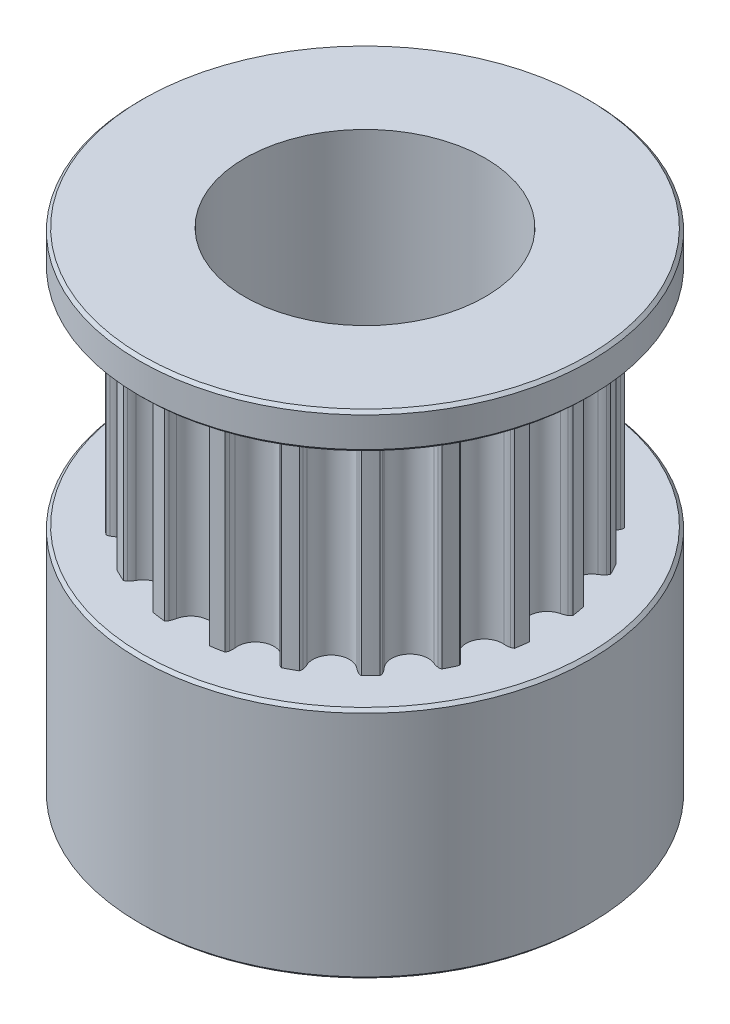
from build123d import *

# Parameters (mm, degrees)
P_IDAT_START            = 7.8
SKICA1_R                = 4
P_IDAT_VYSUNUT_M1_DEPTH = 7.4
SKICA2_R                = 4.5
SKICA2_R_2              = 4
P_IDAT_VYSUNUT_M2_DEPTH = 7.8
SKICA3_R                = 4
SKICA3_R_2              = 3.5
P_IDAT_VYSUNUT_M3_DEPTH = 1.2
SKICA5_R                = 7.5
SKICA5_R_2              = 3.5
P_IDAT_VYSUNUT_M4_DEPTH = 1.2
SKICA6_R                = 7.5
SKICA6_R_2              = 4
P_IDAT_VYSUNUT_M5_DEPTH = 7.8
ZKOSEN_1_SIZE           = 0.1
ZKOSEN_3_SIZE           = 0.1
SKETCH1_R               = 4
CUT_EXTRUDE1_DEPTH      = 2.2


with BuildPart() as part:
    # Skica1 → Přidat vysunutím1 (new body)
    with BuildSketch(Plane(origin=(0, 0, 0), x_dir=(1, 0, 0), z_dir=(0, 1, 0)).offset(P_IDAT_START)):
        with BuildLine():
            ThreePointArc((-5.730143195, 1.098270155), (-5.09645097, 1.530497044), (-5.387174672, 2.240331989))
            ThreePointArc((-5.387174672, 2.240331989), (-5.468060657, 2.292707421), (-5.540463547, 2.356296335))
            ThreePointArc((-5.540463547, 2.356296335), (-5.573874331, 2.399596558), (-5.596043873, 2.44959357))
            ThreePointArc((-5.596043873, 2.44959357), (-5.50369925, 2.650567912), (-5.404139771, 2.848067596))
            ThreePointArc((-5.404139771, 2.848067596), (-5.351227535, 2.86190541), (-5.296542742, 2.862779021))
            ThreePointArc((-5.296542742, 2.862779021), (-5.201685094, 2.845815675), (-5.110305882, 2.815228615))
            ThreePointArc((-5.110305882, 2.815228615), (-4.374063308, 3.030479148), (-4.431206919, 3.795410862))
            ThreePointArc((-4.431206919, 3.795410862), (-4.491949163, 3.870218002), (-4.541158349, 3.953068377))
            ThreePointArc((-4.541158349, 3.953068377), (-4.559553388, 4.004573836), (-4.565187949, 4.058974585))
            ThreePointArc((-4.565187949, 4.058974585), (-4.415258506, 4.221576484), (-4.259541056, 4.378644275))
            ThreePointArc((-4.259541056, 4.378644275), (-4.204942409, 4.375454038), (-4.15266412, 4.359386362))
            ThreePointArc((-4.15266412, 4.359386362), (-4.067691098, 4.313940635), (-3.990236225, 4.256612884))
            ThreePointArc((-3.990236225, 4.256612884), (-3.223511854, 4.233816838), (-3.041481758, 4.978968476))
            ThreePointArc((-3.041481758, 4.978968476), (-3.076134388, 5.06888468), (-3.097332931, 5.162886543))
            ThreePointArc((-3.097332931, 5.162886543), (-3.09891159, 5.217555525), (-3.08745962, 5.271034888))
            ThreePointArc((-3.08745962, 5.271034888), (-2.894621497, 5.379347737), (-2.697988784, 5.480608745))
            ThreePointArc((-2.697988784, 5.480608745), (-2.647048223, 5.460702739), (-2.6022938, 5.429266591))
            ThreePointArc((-2.6022938, 5.429266591), (-2.535523156, 5.359787029), (-2.479574443, 5.281330225))
            ThreePointArc((-2.479574443, 5.281330225), (-1.7574206, 5.022719037), (-1.354035171, 5.675149965))
            ThreePointArc((-1.354035171, 5.675149965), (-1.359206146, 5.771373608), (-1.350318985, 5.867325402))
            ThreePointArc((-1.350318985, 5.867325402), (-1.334926735, 5.919806527), (-1.307509232, 5.967129569))
            ThreePointArc((-1.307509232, 5.967129569), (-1.090638767, 6.010550954), (-0.872338572, 6.046093045))
            ThreePointArc((-0.872338572, 6.046093045), (-0.830042514, 6.01141981), (-0.797192832, 5.967692379))
            ThreePointArc((-0.797192832, 5.967692379), (-0.755160541, 5.880980125), (-0.726194639, 5.789074167))
            ThreePointArc((-0.726194639, 5.789074167), (-0.119300773, 5.319962501), (0.465953812, 5.815808234))
            ThreePointArc((0.465953812, 5.815808234), (0.490770664, 5.908920276), (0.528873591, 5.997429571))
            ThreePointArc((0.528873591, 5.997429571), (0.55973005, 6.04258562), (0.600429269, 6.079120034))
            ThreePointArc((0.600429269, 6.079120034), (0.820103284, 6.053399565), (1.038702217, 6.019743632))
            ThreePointArc((1.038702217, 6.019743632), (1.06821354, 5.973697225), (1.085942924, 5.921958857))
            ThreePointArc((1.085942924, 5.921958857), (1.099122448, 5.826501911), (1.098270155, 5.730143195))
            ThreePointArc((1.098270155, 5.730143195), (1.530497044, 5.09645097), (2.240331989, 5.387174672))
            ThreePointArc((2.240331989, 5.387174672), (2.292707421, 5.468060657), (2.356296335, 5.540463547))
            ThreePointArc((2.356296335, 5.540463547), (2.399596558, 5.573874331), (2.44959357, 5.596043873))
            ThreePointArc((2.44959357, 5.596043873), (2.650567912, 5.50369925), (2.848067596, 5.404139771))
            ThreePointArc((2.848067596, 5.404139771), (2.86190541, 5.351227535), (2.862779021, 5.296542742))
            ThreePointArc((2.862779021, 5.296542742), (2.845815675, 5.201685094), (2.815228615, 5.110305882))
            ThreePointArc((2.815228615, 5.110305882), (3.030479148, 4.374063308), (3.795410862, 4.431206919))
            ThreePointArc((3.795410862, 4.431206919), (3.870218002, 4.491949163), (3.953068377, 4.541158349))
            ThreePointArc((3.953068377, 4.541158349), (4.004573836, 4.559553388), (4.058974585, 4.565187949))
            ThreePointArc((4.058974585, 4.565187949), (4.221576484, 4.415258506), (4.378644275, 4.259541056))
            ThreePointArc((4.378644275, 4.259541056), (4.375454038, 4.204942409), (4.359386362, 4.15266412))
            ThreePointArc((4.359386362, 4.15266412), (4.313940635, 4.067691098), (4.256612884, 3.990236225))
            ThreePointArc((4.256612884, 3.990236225), (4.233816838, 3.223511854), (4.978968476, 3.041481758))
            ThreePointArc((4.978968476, 3.041481758), (5.06888468, 3.076134388), (5.162886543, 3.097332931))
            ThreePointArc((5.162886543, 3.097332931), (5.217555525, 3.09891159), (5.271034888, 3.08745962))
            ThreePointArc((5.271034888, 3.08745962), (5.379347737, 2.894621497), (5.480608745, 2.697988784))
            ThreePointArc((5.480608745, 2.697988784), (5.460702739, 2.647048223), (5.429266591, 2.6022938))
            ThreePointArc((5.429266591, 2.6022938), (5.359787029, 2.535523156), (5.281330225, 2.479574443))
            ThreePointArc((5.281330225, 2.479574443), (5.022719037, 1.7574206), (5.675149965, 1.354035171))
            ThreePointArc((5.675149965, 1.354035171), (5.771373608, 1.359206146), (5.867325402, 1.350318985))
            ThreePointArc((5.867325402, 1.350318985), (5.919806527, 1.334926735), (5.967129569, 1.307509232))
            ThreePointArc((5.967129569, 1.307509232), (6.010550954, 1.090638767), (6.046093045, 0.872338572))
            ThreePointArc((6.046093045, 0.872338572), (6.01141981, 0.830042514), (5.967692379, 0.797192832))
            ThreePointArc((5.967692379, 0.797192832), (5.880980125, 0.755160541), (5.789074167, 0.726194639))
            ThreePointArc((5.789074167, 0.726194639), (5.319962501, 0.119300773), (5.815808234, -0.465953812))
            ThreePointArc((5.815808234, -0.465953812), (5.908920276, -0.490770664), (5.997429571, -0.528873591))
            ThreePointArc((5.997429571, -0.528873591), (6.04258562, -0.55973005), (6.079120034, -0.600429269))
            ThreePointArc((6.079120034, -0.600429269), (6.053399565, -0.820103284), (6.019743632, -1.038702217))
            ThreePointArc((6.019743632, -1.038702217), (5.973697225, -1.06821354), (5.921958857, -1.085942924))
            ThreePointArc((5.921958857, -1.085942924), (5.826501911, -1.099122448), (5.730143195, -1.098270155))
            ThreePointArc((5.730143195, -1.098270155), (5.09645097, -1.530497044), (5.387174672, -2.240331989))
            ThreePointArc((5.387174672, -2.240331989), (5.468060657, -2.292707421), (5.540463547, -2.356296335))
            ThreePointArc((5.540463547, -2.356296335), (5.573874331, -2.399596558), (5.596043873, -2.44959357))
            ThreePointArc((5.596043873, -2.44959357), (5.50369925, -2.650567911), (5.404139771, -2.848067596))
            ThreePointArc((5.404139771, -2.848067596), (5.351227535, -2.86190541), (5.296542742, -2.862779021))
            ThreePointArc((5.296542742, -2.862779021), (5.201685094, -2.845815675), (5.110305882, -2.815228615))
            ThreePointArc((5.110305882, -2.815228615), (4.374063308, -3.030479148), (4.431206919, -3.795410862))
            ThreePointArc((4.431206919, -3.795410862), (4.491949163, -3.870218002), (4.541158349, -3.953068377))
            ThreePointArc((4.541158349, -3.953068377), (4.559553388, -4.004573836), (4.565187949, -4.058974585))
            ThreePointArc((4.565187949, -4.058974585), (4.415258506, -4.221576484), (4.259541056, -4.378644275))
            ThreePointArc((4.259541056, -4.378644275), (4.204942409, -4.375454038), (4.15266412, -4.359386362))
            ThreePointArc((4.15266412, -4.359386362), (4.067691098, -4.313940635), (3.990236225, -4.256612884))
            ThreePointArc((3.990236225, -4.256612884), (3.223511854, -4.233816838), (3.041481758, -4.978968476))
            ThreePointArc((3.041481758, -4.978968476), (3.076134388, -5.06888468), (3.097332931, -5.162886543))
            ThreePointArc((3.097332931, -5.162886543), (3.09891159, -5.217555525), (3.08745962, -5.271034888))
            ThreePointArc((3.08745962, -5.271034888), (2.894621497, -5.379347737), (2.697988784, -5.480608745))
            ThreePointArc((2.697988784, -5.480608745), (2.647048223, -5.460702739), (2.6022938, -5.429266591))
            ThreePointArc((2.6022938, -5.429266591), (2.535523156, -5.359787029), (2.479574443, -5.281330225))
            ThreePointArc((2.479574443, -5.281330225), (1.7574206, -5.022719037), (1.354035171, -5.675149965))
            ThreePointArc((1.354035171, -5.675149965), (1.359206146, -5.771373608), (1.350318985, -5.867325402))
            ThreePointArc((1.350318985, -5.867325402), (1.334926735, -5.919806527), (1.307509232, -5.967129569))
            ThreePointArc((1.307509232, -5.967129569), (1.090638767, -6.010550954), (0.872338572, -6.046093045))
            ThreePointArc((0.872338572, -6.046093045), (0.830042514, -6.01141981), (0.797192832, -5.967692379))
            ThreePointArc((0.797192832, -5.967692379), (0.755160541, -5.880980125), (0.726194639, -5.789074167))
            ThreePointArc((0.726194639, -5.789074167), (0.119300773, -5.319962501), (-0.465953812, -5.815808234))
            ThreePointArc((-0.465953812, -5.815808234), (-0.490770664, -5.908920276), (-0.528873591, -5.997429571))
            ThreePointArc((-0.528873591, -5.997429571), (-0.55973005, -6.04258562), (-0.600429269, -6.079120034))
            ThreePointArc((-0.600429269, -6.079120034), (-0.820103284, -6.053399565), (-1.038702217, -6.019743632))
            ThreePointArc((-1.038702217, -6.019743632), (-1.06821354, -5.973697225), (-1.085942924, -5.921958857))
            ThreePointArc((-1.085942924, -5.921958857), (-1.099122448, -5.826501911), (-1.098270155, -5.730143195))
            ThreePointArc((-1.098270155, -5.730143195), (-1.530497044, -5.09645097), (-2.240331989, -5.387174672))
            ThreePointArc((-2.240331989, -5.387174672), (-2.292707421, -5.468060657), (-2.356296335, -5.540463547))
            ThreePointArc((-2.356296335, -5.540463547), (-2.399596558, -5.573874331), (-2.44959357, -5.596043873))
            ThreePointArc((-2.44959357, -5.596043873), (-2.650567912, -5.50369925), (-2.848067596, -5.404139771))
            ThreePointArc((-2.848067596, -5.404139771), (-2.86190541, -5.351227535), (-2.862779021, -5.296542742))
            ThreePointArc((-2.862779021, -5.296542742), (-2.845815675, -5.201685094), (-2.815228615, -5.110305882))
            ThreePointArc((-2.815228615, -5.110305882), (-3.030479148, -4.374063308), (-3.795410862, -4.431206919))
            ThreePointArc((-3.795410862, -4.431206919), (-3.870218002, -4.491949163), (-3.953068377, -4.541158349))
            ThreePointArc((-3.953068377, -4.541158349), (-4.004573836, -4.559553388), (-4.058974585, -4.565187949))
            ThreePointArc((-4.058974585, -4.565187949), (-4.221576484, -4.415258506), (-4.378644275, -4.259541056))
            ThreePointArc((-4.378644275, -4.259541056), (-4.375454038, -4.204942409), (-4.359386362, -4.15266412))
            ThreePointArc((-4.359386362, -4.15266412), (-4.313940635, -4.067691098), (-4.256612884, -3.990236225))
            ThreePointArc((-4.256612884, -3.990236225), (-4.233816838, -3.223511854), (-4.978968476, -3.041481758))
            ThreePointArc((-4.978968476, -3.041481758), (-5.06888468, -3.076134388), (-5.162886543, -3.097332931))
            ThreePointArc((-5.162886543, -3.097332931), (-5.217555525, -3.09891159), (-5.271034888, -3.08745962))
            ThreePointArc((-5.271034888, -3.08745962), (-5.379347737, -2.894621497), (-5.480608745, -2.697988784))
            ThreePointArc((-5.480608745, -2.697988784), (-5.460702739, -2.647048223), (-5.429266591, -2.6022938))
            ThreePointArc((-5.429266591, -2.6022938), (-5.359787029, -2.535523156), (-5.281330225, -2.479574443))
            ThreePointArc((-5.281330225, -2.479574443), (-5.022719037, -1.7574206), (-5.675149965, -1.354035171))
            ThreePointArc((-5.675149965, -1.354035171), (-5.771373608, -1.359206146), (-5.867325402, -1.350318985))
            ThreePointArc((-5.867325402, -1.350318985), (-5.919806527, -1.334926735), (-5.967129569, -1.307509232))
            ThreePointArc((-5.967129569, -1.307509232), (-6.010550954, -1.090638767), (-6.046093045, -0.872338572))
            ThreePointArc((-6.046093045, -0.872338572), (-6.01141981, -0.830042514), (-5.967692379, -0.797192832))
            ThreePointArc((-5.967692379, -0.797192832), (-5.880980125, -0.755160541), (-5.789074167, -0.726194639))
            ThreePointArc((-5.789074167, -0.726194639), (-5.319962501, -0.119300773), (-5.815808234, 0.465953812))
            ThreePointArc((-5.815808234, 0.465953812), (-5.908920276, 0.490770664), (-5.997429571, 0.528873591))
            ThreePointArc((-5.997429571, 0.528873591), (-6.04258562, 0.55973005), (-6.079120034, 0.600429269))
            ThreePointArc((-6.079120034, 0.600429269), (-6.053399565, 0.820103284), (-6.019743632, 1.038702217))
            ThreePointArc((-6.019743632, 1.038702217), (-5.973697225, 1.06821354), (-5.921958857, 1.085942924))
            ThreePointArc((-5.921958857, 1.085942924), (-5.826501911, 1.099122448), (-5.730143195, 1.098270155))
        make_face()
        Circle(SKICA1_R, mode=Mode.SUBTRACT)
    extrude(amount=P_IDAT_VYSUNUT_M1_DEPTH)

    # Skica2 → Přidat vysunutím2 (add)
    with BuildSketch(Plane.XZ.offset(-7.8)):
        Circle(SKICA2_R)
        Circle(SKICA2_R_2, mode=Mode.SUBTRACT)
    extrude(amount=P_IDAT_VYSUNUT_M2_DEPTH)


with BuildPart() as body_2:
    # Skica3 → Přidat vysunutím3 (new body)
    with BuildSketch(Plane(origin=(0, 15.2, 0), x_dir=(1, 0, 0), z_dir=(0, 1, 0))):
        Circle(SKICA3_R)
        Circle(SKICA3_R_2, mode=Mode.SUBTRACT)
    extrude(amount=P_IDAT_VYSUNUT_M3_DEPTH)


with BuildPart() as body_3:
    # Skica5 → Přidat vysunutím4 (new body)
    with BuildSketch(Plane(origin=(0, 16.4, 0), x_dir=(1, 0, 0), z_dir=(0, 1, 0))):
        Circle(SKICA5_R)
        Circle(SKICA5_R_2, mode=Mode.SUBTRACT)
    extrude(amount=-P_IDAT_VYSUNUT_M4_DEPTH)

    # Zkosení1
    zkosen_1_edges = [body_3.edges().sort_by_distance(p)[0] for p in [
        (-7.5, 16.4, 0),
        (-7.5, 15.2, 0),
    ]]
    chamfer(zkosen_1_edges, length=ZKOSEN_1_SIZE)


with BuildPart() as body_4:
    # Skica6 → Přidat vysunutím5 (new body)
    with BuildSketch(Plane.XZ):
        Circle(SKICA6_R)
        Circle(SKICA6_R_2, mode=Mode.SUBTRACT)
    extrude(amount=-P_IDAT_VYSUNUT_M5_DEPTH)

    # Zkosení3
    zkosen_3_edges = [body_4.edges().sort_by_distance(p)[0] for p in [
        (-7.5, 0, 0),
        (-7.5, 7.8, 0),
    ]]
    chamfer(zkosen_3_edges, length=ZKOSEN_3_SIZE)


with BuildPart() as part_1:
    add(part.part)

    # Combine1: union body 3, body 2, body 4
    add(body_3.part)
    add(body_2.part)
    add(body_4.part)

    # Sketch1 → Cut-Extrude1 (cut, through all)
    with BuildSketch(Plane.XZ.offset(-15.2)):
        Circle(SKETCH1_R)
    extrude(amount=-CUT_EXTRUDE1_DEPTH, mode=Mode.SUBTRACT)


solid = part_1.part
